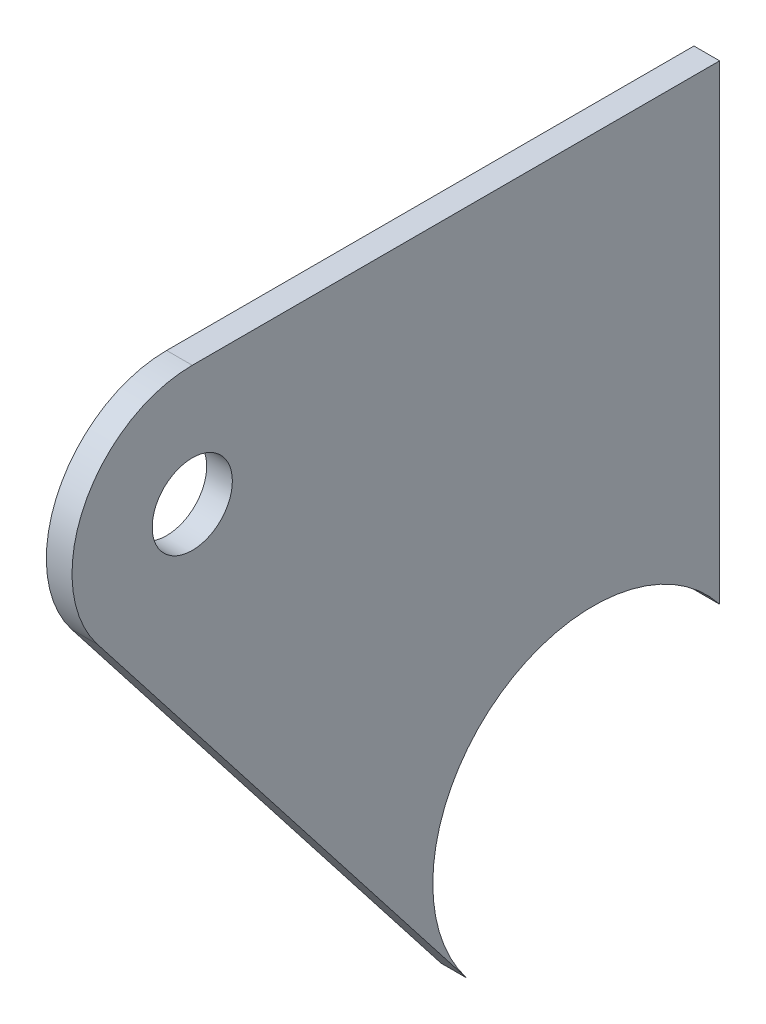
from build123d import *

# Parameters (mm, degrees)
BOSS_EXTRUDE1_START = 12.7
SKETCH1_R           = 3.175
BOSS_EXTRUDE1_DEPTH = 2.032


with BuildPart() as part:
    # Sketch1 → Boss-Extrude1 (new body)
    with BuildSketch(Plane(origin=(0, 0, 0), x_dir=(0, 0, -1), z_dir=(1, 0, 0)).offset(BOSS_EXTRUDE1_START)):
        with BuildLine():
            Line((-10.015716817, -7.808675729), (-39.261787613, 29.703493203))
            ThreePointArc((-39.261787613, 29.703493203), (-40.308879957, 39.739856323), (-31.75, 45.085))
            Line((-31.75, 45.085), (10.015716817, 45.085))
            Line((10.015716817, 45.085), (10.015716817, 7.808675729))
            ThreePointArc((10.015716817, 7.808675729), (-7.808675729, 10.015716817), (-10.015716817, -7.808675729))
        make_face()
        with Locations((-31.75, 35.56)):
            Circle(SKETCH1_R, mode=Mode.SUBTRACT)
    extrude(amount=BOSS_EXTRUDE1_DEPTH)


solid = part.part
